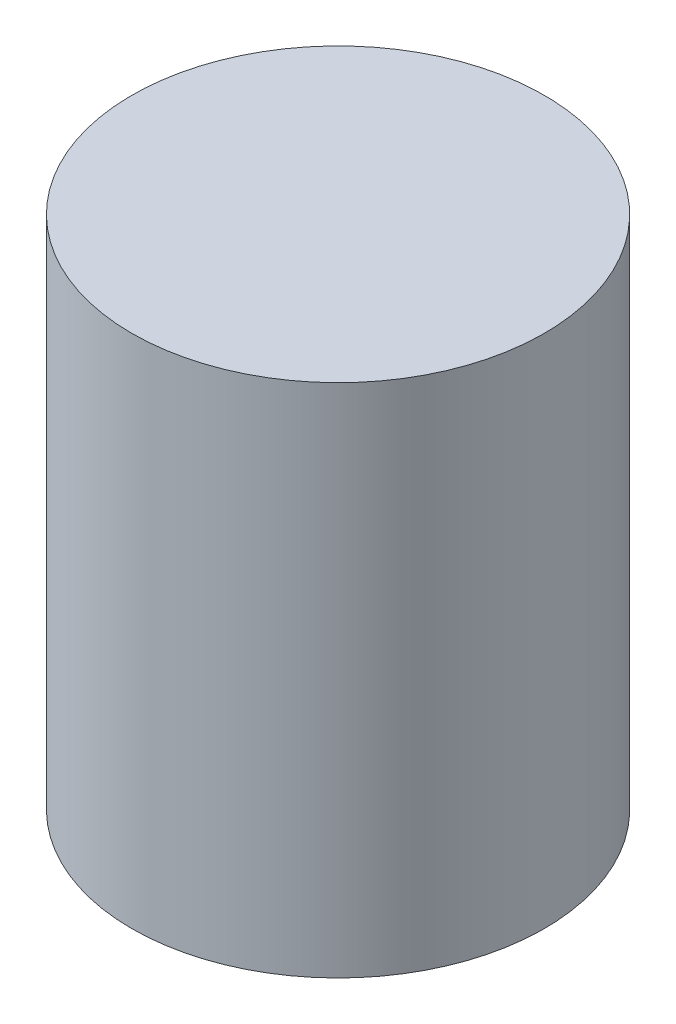
from build123d import *

# Parameters (mm, degrees)
SKETCH_1_R      = 10
EXTRUDE_1_DEPTH = 25


with BuildPart() as part:
    # Эскиз1 → Бобышка-Вытянуть1 (new body)
    with BuildSketch(Plane(origin=(0, 0, 0), x_dir=(1, 0, 0), z_dir=(0, 1, 0))):
        Circle(SKETCH_1_R)
    extrude(amount=EXTRUDE_1_DEPTH)


solid = part.part
